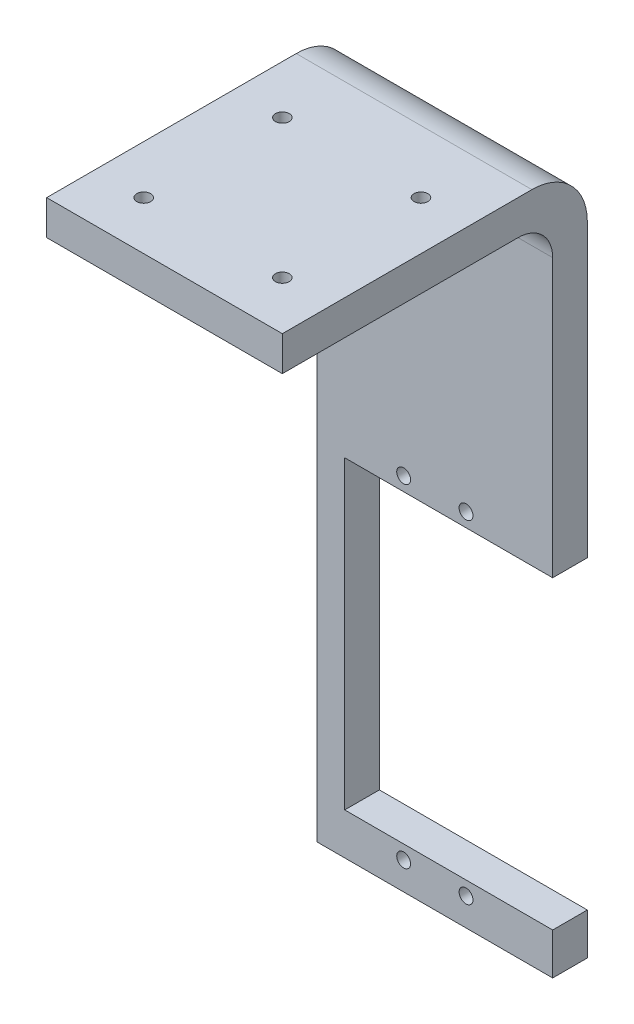
from build123d import *

# Parameters (mm, degrees)
SKETCH1_R           = 1
BOSS_EXTRUDE1_DEPTH = 5
SKETCH2_W           = 34
SKETCH2_H           = 44
SKETCH2_R           = 1
BOSS_EXTRUDE2_DEPTH = 5
FILLET1_R           = 8
FILLET3_R           = 5


with BuildPart() as part:
    # Sketch1 → Boss-Extrude1 (new body)
    with BuildSketch(Plane.XY):
        Polygon((-17, 67), (-17, -28), (17, -28), (17, -22), (13, -22), (-13, -22), (-13, -21.411764706), (-13, 22), (13, 22), (17, 22), (17, 67), align=None)
        with Locations((-4.5, -24)):
            Circle(SKETCH1_R, mode=Mode.SUBTRACT)
        with Locations((4.5, -24)):
            Circle(SKETCH1_R, mode=Mode.SUBTRACT)
        with Locations((-4.5, 24)):
            Circle(SKETCH1_R, mode=Mode.SUBTRACT)
        with Locations((4.5, 24)):
            Circle(SKETCH1_R, mode=Mode.SUBTRACT)
    extrude(amount=BOSS_EXTRUDE1_DEPTH)

    # Sketch2 → Boss-Extrude2 (add)
    with BuildSketch(Plane(origin=(0, 67, 0), x_dir=(1, 0, 0), z_dir=(0, 1, 0))):
        with Locations((0, -22)):
            Rectangle(SKETCH2_W, SKETCH2_H)
        with Locations((-10, -17)):
            Circle(SKETCH2_R, mode=Mode.SUBTRACT)
        with Locations((10, -17)):
            Circle(SKETCH2_R, mode=Mode.SUBTRACT)
        with Locations((10, -37)):
            Circle(SKETCH2_R, mode=Mode.SUBTRACT)
        with Locations((-10, -37)):
            Circle(SKETCH2_R, mode=Mode.SUBTRACT)
    extrude(amount=BOSS_EXTRUDE2_DEPTH)

    # Fillet1
    fillet1_edges = [part.edges().sort_by_distance(p)[0] for p in [
        (0, 72, 0),
    ]]
    fillet(fillet1_edges, radius=FILLET1_R)

    # Fillet3
    fillet3_edges = [part.edges().sort_by_distance(p)[0] for p in [
        (0, 67, 5),
    ]]
    fillet(fillet3_edges, radius=FILLET3_R)


solid = part.part
